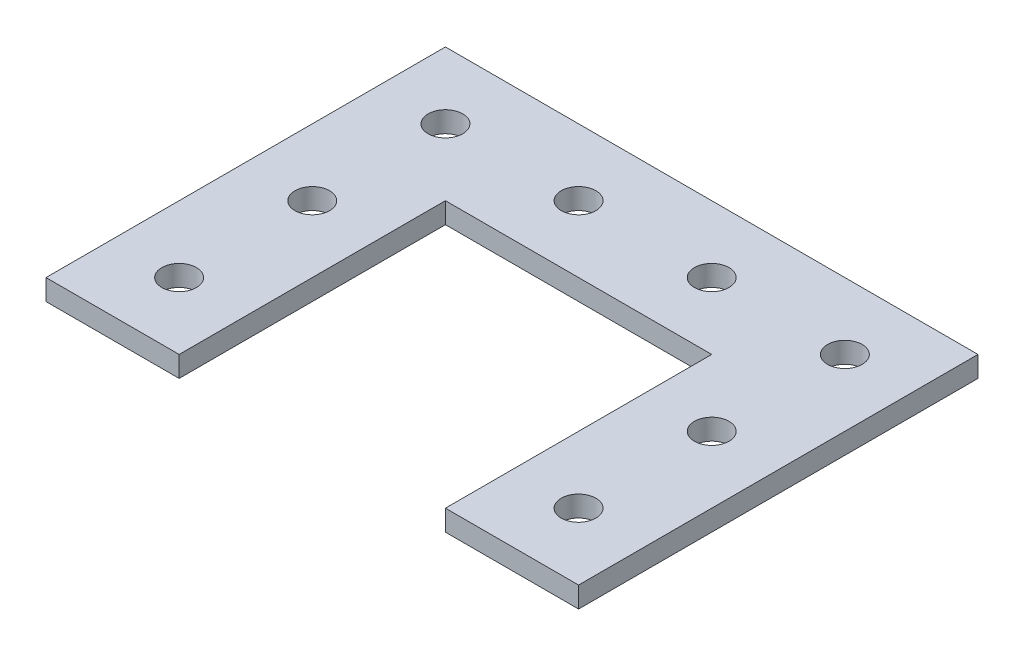
from build123d import *

# Parameters (mm, degrees)
SKETCH1_R           = 2.6
BOSS_EXTRUDE1_DEPTH = 3.125


with BuildPart() as part:
    # Sketch1 → Boss-Extrude1 (new body)
    with BuildSketch(Plane(origin=(0, 0, 0), x_dir=(1, 0, 0), z_dir=(0, 1, 0))):
        Polygon((0, 0), (0, 60), (80, 60), (80, 0), (60, 0), (60, 40), (20, 40), (20, 0), align=None)
        with Locations((10, 50)):
            Circle(SKETCH1_R, mode=Mode.SUBTRACT)
        with Locations((10, 30)):
            Circle(SKETCH1_R, mode=Mode.SUBTRACT)
        with Locations((10, 10)):
            Circle(SKETCH1_R, mode=Mode.SUBTRACT)
        with Locations((30, 50)):
            Circle(SKETCH1_R, mode=Mode.SUBTRACT)
        with Locations((50, 50)):
            Circle(SKETCH1_R, mode=Mode.SUBTRACT)
        with Locations((70, 50)):
            Circle(SKETCH1_R, mode=Mode.SUBTRACT)
        with Locations((70, 30)):
            Circle(SKETCH1_R, mode=Mode.SUBTRACT)
        with Locations((70, 10)):
            Circle(SKETCH1_R, mode=Mode.SUBTRACT)
    extrude(amount=BOSS_EXTRUDE1_DEPTH)


solid = part.part
